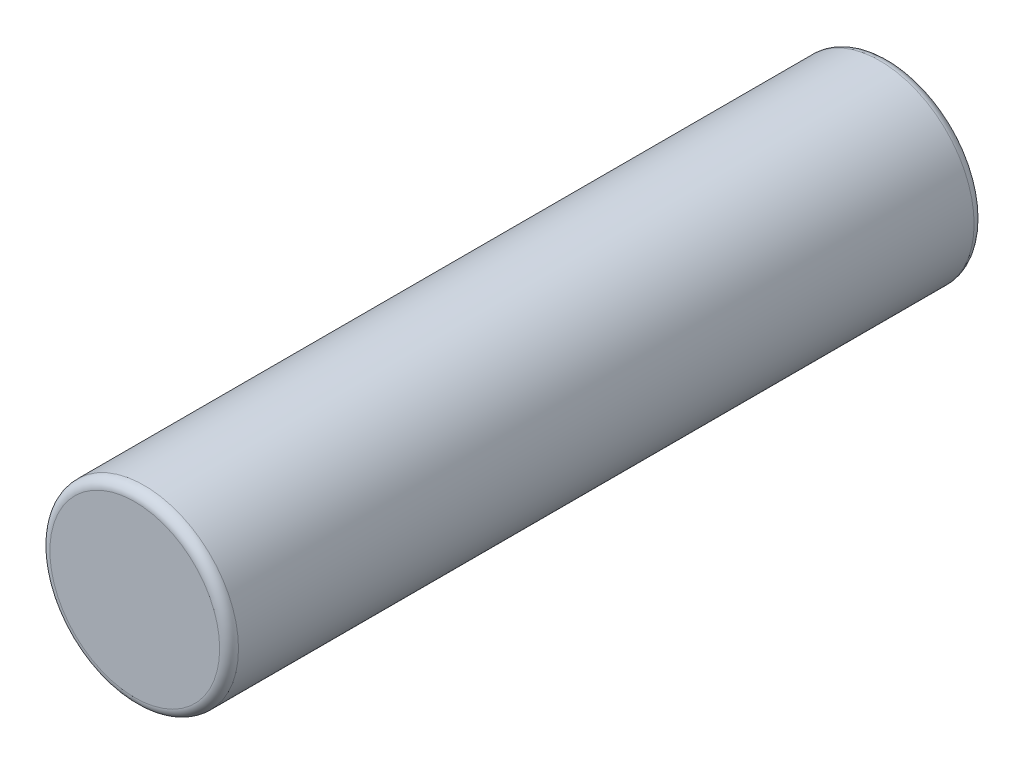
from build123d import *

# Parameters (mm, degrees)
SKETCH2_R           = 1
BOSS_EXTRUDE1_DEPTH = 8
FILLET1_R           = 0.1


with BuildPart() as part:
    # Sketch2 → Boss-Extrude1 (new body)
    with BuildSketch(Plane.XY):
        Circle(SKETCH2_R)
    extrude(amount=BOSS_EXTRUDE1_DEPTH)

    # Fillet1
    fillet1_edges = [part.edges().sort_by_distance(p)[0] for p in [
        (-1, 0, 0),
        (-1, 0, 8),
    ]]
    fillet(fillet1_edges, radius=FILLET1_R)


solid = part.part
